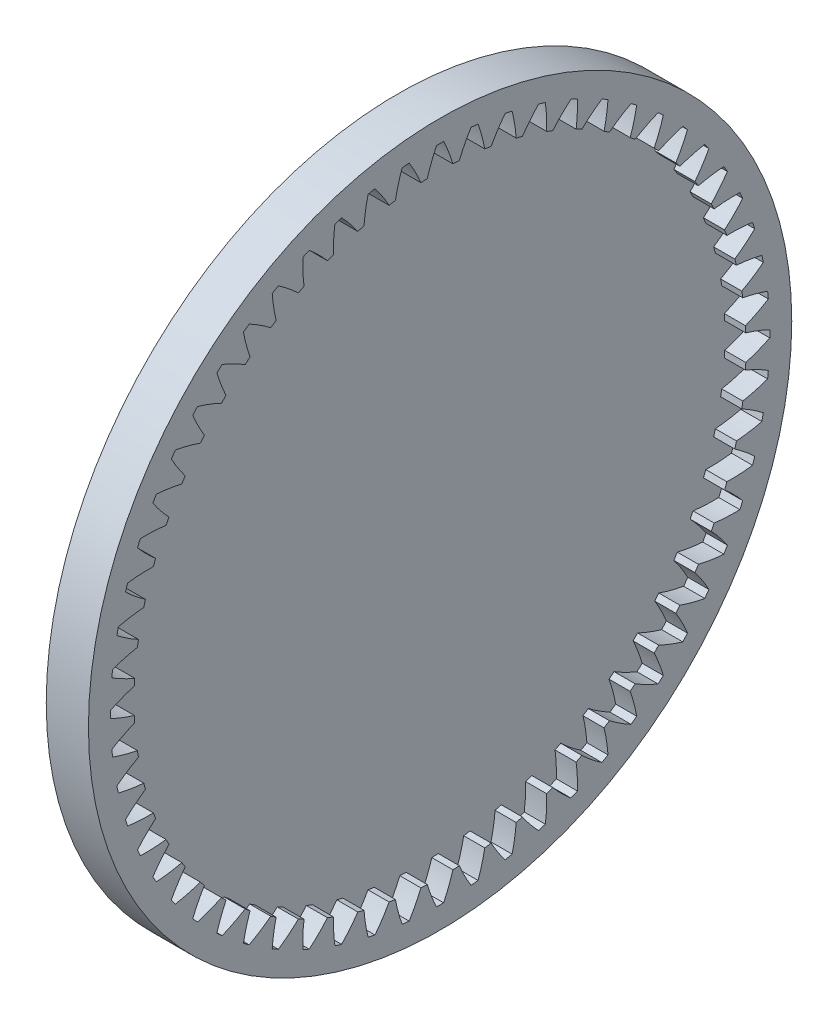
from build123d import *

# Parameters (mm, degrees)
BASPROSKE_W         = 12
BASPROSKE_H         = 13
TOOTHCUT_DEPTH      = 142.929559994
TEETHCUTS_COUNT     = 60
TEETHCUTS_ANGLE     = 354
BOSS_EXTRUDE1_START = -6
SKETCH1_R           = 100
BOSS_EXTRUDE1_DEPTH = 6


with BuildPart() as part:
    # BasProSke → Base-Revolve (revolve)
    with BuildSketch(Plane(origin=(0, 0, 0), x_dir=(1, 0, 0), z_dir=(0, 1, 0))):
        with Locations((6, 93.5)):
            Rectangle(BASPROSKE_W, BASPROSKE_H)
    revolve(axis=Axis((-10, 0, 0), (1, 0, 0)))

    # TooCutSke → ToothCut (cut, through all)
    with BuildSketch(Plane(origin=(0, 0, 0), x_dir=(0, 0, -1), z_dir=(1, 0, 0))):
        with BuildLine():
            ThreePointArc((3.64944484, 86.898001114), (2.46565463, 90.375900508), (1.002106965, 93.745644073))
            ThreePointArc((1.002106965, 93.745644073), (0, 93.751), (-1.002106965, 93.745644073))
            ThreePointArc((-1.002106965, 93.745644073), (-2.46565463, 90.375900508), (-3.64944484, 86.898001114))
            ThreePointArc((-3.64944484, 86.898001114), (0, 86.9746), (3.64944484, 86.898001114))
        make_face()
    toothcut = extrude(amount=TOOTHCUT_DEPTH, mode=Mode.SUBTRACT)

    # TeethCuts: ToothCut ×60 about axis
    teethcuts_axis = Axis((-10, 0, 0), (1, 0, 0))
    for i in range(1, TEETHCUTS_COUNT):
        add(toothcut.rotate(teethcuts_axis, i * TEETHCUTS_ANGLE / (TEETHCUTS_COUNT - 1)), mode=Mode.SUBTRACT)

    # Sketch1 → Boss-Extrude1 (add)
    with BuildSketch(Plane.ZY.offset(BOSS_EXTRUDE1_START)):
        Circle(SKETCH1_R)
    extrude(amount=BOSS_EXTRUDE1_DEPTH)


solid = part.part
